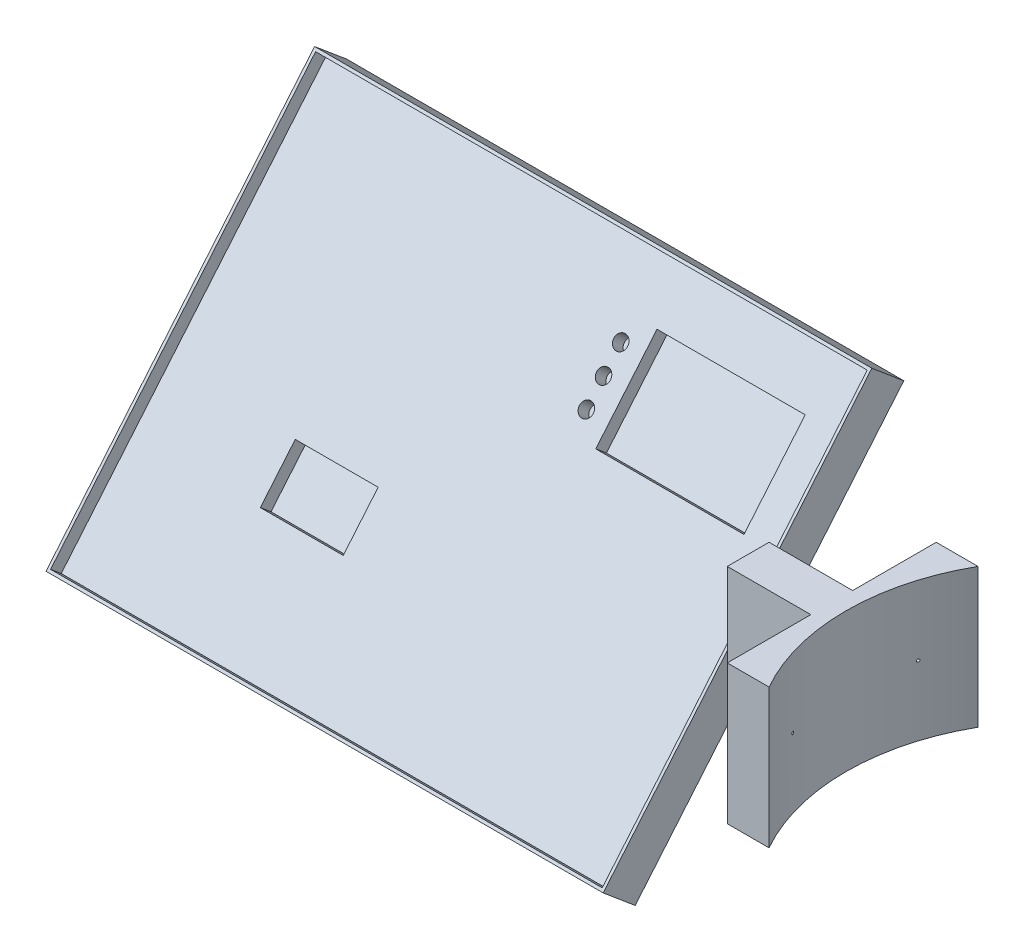
from build123d import *

# Parameters (mm, degrees)
BOSS_EXTRU_1_DEPTH      = 100
BOSS_EXTRU_2_DEPTH      = 400
ESQUISSE3_W             = 396
ESQUISSE3_H             = 296
ESQUISSE3_W_2           = 59.5
ESQUISSE3_H_2           = 39
ESQUISSE3_R             = 5
ESQUISSE3_W_3           = 106.4
ESQUISSE3_H_3           = 68.4
ENL_V_MAT_EXTRU_1_DEPTH = 10
ESQUISSE3_3_W           = 106.4
ESQUISSE3_3_H           = 68.4
ESQUISSE3_3_W_2         = 59.5
ESQUISSE3_3_H_2         = 39
ESQUISSE3_3_R           = 5
ENL_V_MAT_EXTRU_2_DEPTH = 20
ESQUISSE4_R             = 1
ENL_V_MAT_EXTRU_3_DEPTH = 60


with BuildPart() as part:
    # Esquisse1 → Boss.-Extru.1 (new body)
    with BuildSketch(Plane(origin=(0, 0, 0), x_dir=(1, 0, 0), z_dir=(0, 1, 0))):
        with BuildLine():
            Line((30, 15), (30, 75))
            Line((30, 75), (60, 75))
            ThreePointArc((60, 75), (40.208169188, 0), (60, -75))
            Line((60, -75), (30, -75))
            Line((30, -75), (30, -15))
            Line((30, -15), (-30, -15))
            Line((-30, -15), (-30, 15))
            Line((-30, 15), (30, 15))
        make_face()
    extrude(amount=BOSS_EXTRU_1_DEPTH)

    # Esquisse2 → Boss.-Extru.2 (add)
    with BuildSketch(Plane.ZY.offset(30)):
        Polygon((-111.739030315, 152.050914274), (81.097252591, -77.762418662), (104.078585884, -58.478790371), (-88.757697022, 171.334542565), align=None)
    extrude(amount=BOSS_EXTRU_2_DEPTH)

    # Esquisse3 → Enl_v. mat.-Extru.1 (cut)
    with BuildSketch(Plane(origin=(0, 27.086671655, 32.280638256), x_dir=(1, 0, 0), z_dir=(0, 0.6427876096865351, 0.7660444431189816))):
        with Locations((-230, 38.302222156)):
            Rectangle(ESQUISSE3_W, ESQUISSE3_H)
        with Locations((-306.627943765, -10.369216509)):
            Rectangle(ESQUISSE3_W_2, ESQUISSE3_H_2, mode=Mode.SUBTRACT)
        with Locations((-183.579130296, 96.504442653)):
            Circle(ESQUISSE3_R, mode=Mode.SUBTRACT)
        with Locations((-183.579130296, 115.704442653)):
            Circle(ESQUISSE3_R, mode=Mode.SUBTRACT)
        with Locations((-183.579130296, 134.904442653)):
            Circle(ESQUISSE3_R, mode=Mode.SUBTRACT)
        with Locations((-113.975273558, 115.704442653)):
            Rectangle(ESQUISSE3_W_3, ESQUISSE3_H_3, mode=Mode.SUBTRACT)
    extrude(amount=-ENL_V_MAT_EXTRU_1_DEPTH, mode=Mode.SUBTRACT)

    # Esquisse3_3 → Enl_v. mat.-Extru.2 (cut)
    with BuildSketch(Plane(origin=(0, 27.086671655, 32.280638256), x_dir=(1, 0, 0), z_dir=(0, 0.6427876096865351, 0.7660444431189816))):
        with Locations((-113.975273558, 115.704442653)):
            Rectangle(ESQUISSE3_3_W, ESQUISSE3_3_H)
        with Locations((-306.627943765, -10.369216509)):
            Rectangle(ESQUISSE3_3_W_2, ESQUISSE3_3_H_2)
        with Locations((-183.579130296, 134.904442653)):
            Circle(ESQUISSE3_3_R)
        with Locations((-183.579130296, 115.704442653)):
            Circle(ESQUISSE3_3_R)
        with Locations((-183.579130296, 96.504442653)):
            Circle(ESQUISSE3_3_R)
    extrude(amount=-ENL_V_MAT_EXTRU_2_DEPTH, mode=Mode.SUBTRACT)

    # Esquisse4 → Enl_v. mat.-Extru.3 (cut)
    with BuildSketch(Plane.ZY.offset(-30)):
        with Locations((-45, 50)):
            Circle(ESQUISSE4_R)
        with Locations((45, 50)):
            Circle(ESQUISSE4_R)
    extrude(amount=-ENL_V_MAT_EXTRU_3_DEPTH, mode=Mode.SUBTRACT)


solid = part.part
